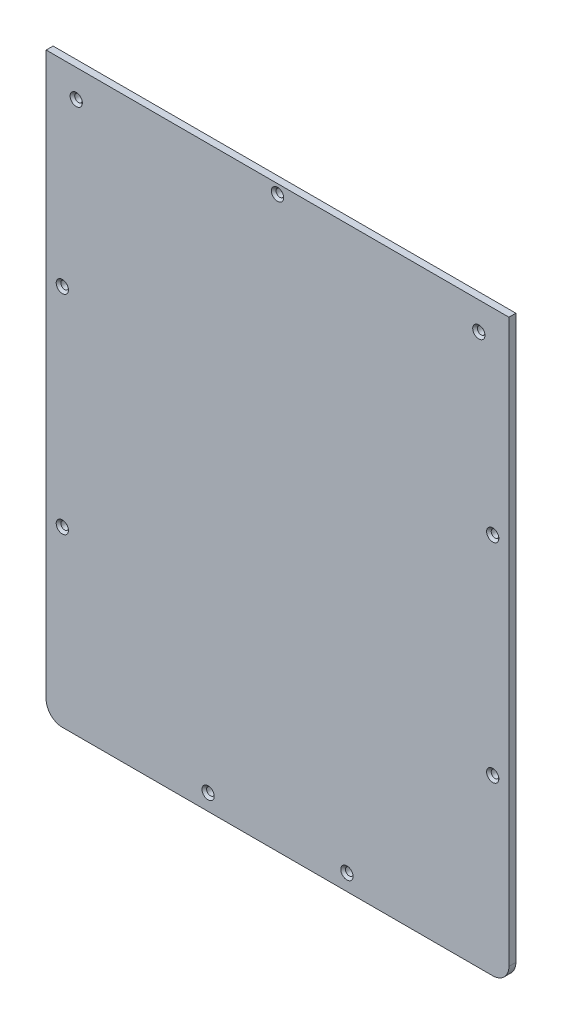
from build123d import *

# Parameters (mm, degrees)
SKETCH1_W           = 200
SKETCH1_H           = 250
BOSS_EXTRUDE1_DEPTH = 3
FILLET1_R           = 7
SKETCH2_R           = 1.65
CUT_EXTRUDE2_DEPTH  = 4
CHAMFER1_SIZE       = 1


with BuildPart() as part:
    # Sketch1 → Boss-Extrude1 (new body)
    with BuildSketch(Plane.XY):
        with Locations((100, 125)):
            Rectangle(SKETCH1_W, SKETCH1_H)
    extrude(amount=BOSS_EXTRUDE1_DEPTH)

    # Fillet1
    fillet1_edges = [part.edges().sort_by_distance(p)[0] for p in [
        (200, 0, 1.5),
        (0, 0, 1.5),
    ]]
    fillet(fillet1_edges, radius=FILLET1_R)

    # Sketch2 → Cut-Extrude2 (cut, through all)
    with BuildSketch(Plane.XY):
        with Locations((70, 7)):
            Circle(SKETCH2_R)
        with Locations((7, 75)):
            Circle(SKETCH2_R)
        with Locations((193, 75)):
            Circle(SKETCH2_R)
        with Locations((13, 238)):
            Circle(SKETCH2_R)
        with Locations((100, 246)):
            Circle(SKETCH2_R)
        with Locations((187, 238)):
            Circle(SKETCH2_R)
        with Locations((7, 165)):
            Circle(SKETCH2_R)
        with Locations((193, 165)):
            Circle(SKETCH2_R)
        with Locations((130, 7)):
            Circle(SKETCH2_R)
    extrude(amount=CUT_EXTRUDE2_DEPTH, mode=Mode.SUBTRACT)

    # Chamfer1
    chamfer1_edges = [part.edges().sort_by_distance(p)[0] for p in [
        (5.35, 75, 3),
        (191.35, 75, 3),
        (11.35, 238, 3),
        (98.35, 246, 3),
        (128.35, 7, 3),
        (191.35, 165, 3),
        (5.35, 165, 3),
        (185.35, 238, 3),
        (68.35, 7, 3),
    ]]
    chamfer(chamfer1_edges, length=CHAMFER1_SIZE)


solid = part.part
